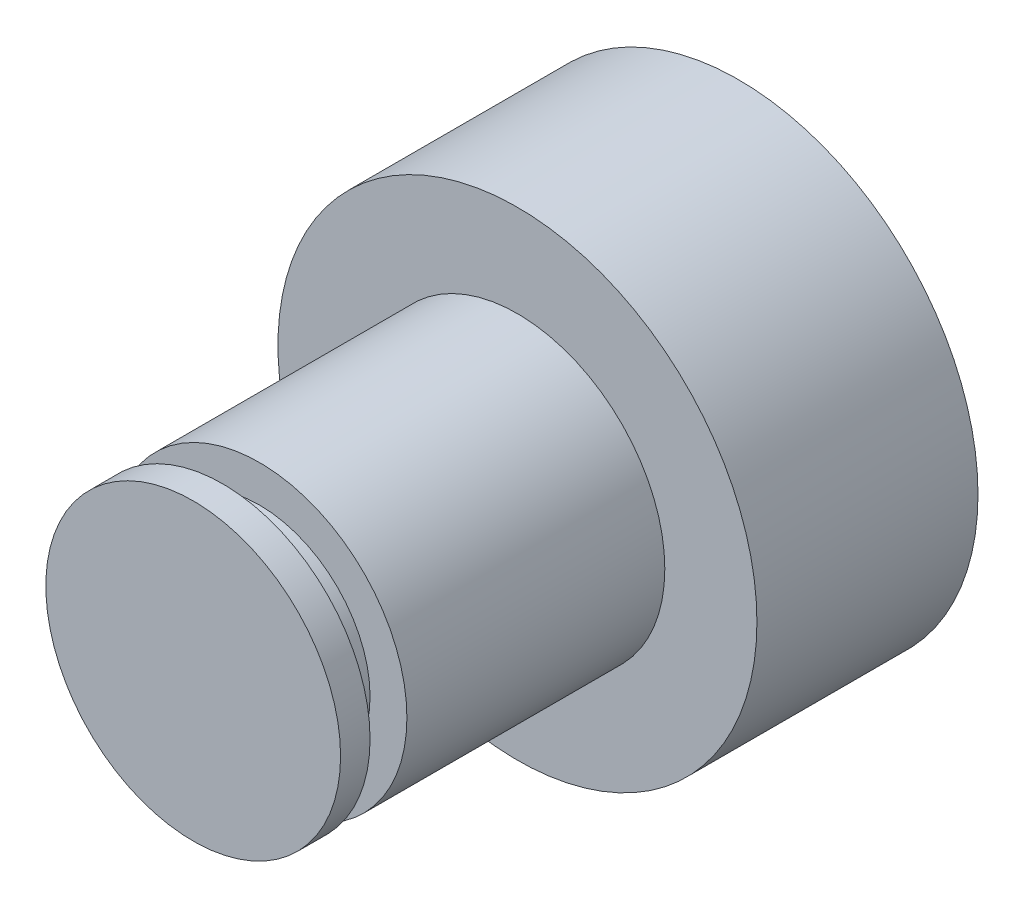
from build123d import *

# Parameters (mm, degrees)
SKETCH1_R           = 6.5
BOSS_EXTRUDE1_DEPTH = 6
SKETCH2_R           = 4
BOSS_EXTRUDE2_DEPTH = 8.8
SKETCH3_R           = 4
SKETCH3_R_2         = 3
CUT_EXTRUDE1_DEPTH  = 0.5


with BuildPart() as part:
    # Sketch1 → Boss-Extrude1 (new body)
    with BuildSketch(Plane.XY):
        Circle(SKETCH1_R)
    extrude(amount=-BOSS_EXTRUDE1_DEPTH)

    # Sketch2 → Boss-Extrude2 (add)
    with BuildSketch(Plane.XY):
        Circle(SKETCH2_R)
    extrude(amount=BOSS_EXTRUDE2_DEPTH)

    # Sketch3 → Cut-Extrude1 (cut, symmetric)
    with BuildSketch(Plane.XY.offset(7.5)):
        Circle(SKETCH3_R)
        Circle(SKETCH3_R_2, mode=Mode.SUBTRACT)
    extrude(amount=CUT_EXTRUDE1_DEPTH, both=True, mode=Mode.SUBTRACT)


solid = part.part
